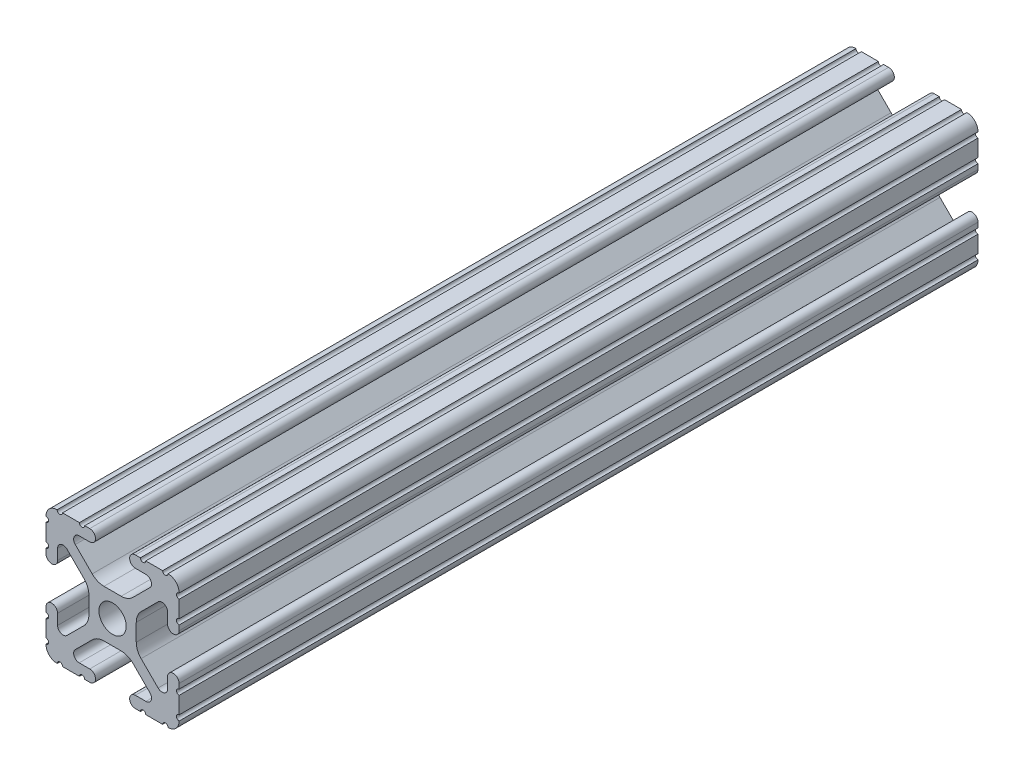
from build123d import *

# Parameters (mm, degrees)
SKETCH11_R              = 2.6035
FRACTIONAL_1010_1_DEPTH = 152.4


with BuildPart() as part:
    # Sketch11 → Fractional 1010(1) (new body)
    with BuildSketch(Plane.YX.offset(-76.2)):
        with BuildLine():
            Line((10.5918, 12.7), (10.5664, 12.7))
            ThreePointArc((10.5664, 12.7), (10.0584, 12.192), (9.5504, 12.7))
            Line((9.5504, 12.7), (6.3246, 12.7))
            ThreePointArc((6.3246, 12.7), (5.8166, 12.192), (5.3086, 12.7))
            Line((5.3086, 12.7), (4.3561, 12.7))
            ThreePointArc((4.3561, 12.7), (3.2512, 11.5951), (4.3561, 10.4902))
            Line((4.3561, 10.4902), (6.370083786, 10.4902))
            ThreePointArc((6.370083786, 10.4902), (7.348856743, 9.836204819), (7.119204175, 8.681663397))
            Line((7.119204175, 8.681663397), (3.88464389, 5.447103113))
            ThreePointArc((3.88464389, 5.447103113), (2.854599758, 4.758849627), (1.63957986, 4.517167143))
            Line((1.63957986, 4.517167143), (-1.63957986, 4.517167143))
            ThreePointArc((-1.63957986, 4.517167143), (-2.854599758, 4.758849627), (-3.88464389, 5.447103113))
            Line((-3.88464389, 5.447103113), (-7.119204175, 8.681663397))
            ThreePointArc((-7.119204175, 8.681663397), (-7.348856743, 9.836204819), (-6.370083786, 10.4902))
            Line((-6.370083786, 10.4902), (-4.3561, 10.4902))
            ThreePointArc((-4.3561, 10.4902), (-3.2512, 11.5951), (-4.3561, 12.7))
            Line((-4.3561, 12.7), (-5.3086, 12.7))
            ThreePointArc((-5.3086, 12.7), (-5.8166, 12.192), (-6.3246, 12.7))
            Line((-6.3246, 12.7), (-9.5504, 12.7))
            ThreePointArc((-9.5504, 12.7), (-10.0584, 12.192), (-10.5664, 12.7))
            Line((-10.5664, 12.7), (-10.5918, 12.7))
            ThreePointArc((-10.5918, 12.7), (-12.082522516, 12.082522516), (-12.7, 10.5918))
            Line((-12.7, 10.5918), (-12.7, 10.5664))
            ThreePointArc((-12.7, 10.5664), (-12.192, 10.0584), (-12.7, 9.5504))
            Line((-12.7, 9.5504), (-12.7, 6.3246))
            ThreePointArc((-12.7, 6.3246), (-12.192, 5.8166), (-12.7, 5.3086))
            Line((-12.7, 5.3086), (-12.7, 4.3561))
            ThreePointArc((-12.7, 4.3561), (-11.5951, 3.2512), (-10.4902, 4.3561))
            Line((-10.4902, 4.3561), (-10.4902, 6.370083786))
            ThreePointArc((-10.4902, 6.370083786), (-9.836204819, 7.348856743), (-8.681663397, 7.119204175))
            Line((-8.681663397, 7.119204175), (-5.447103113, 3.88464389))
            ThreePointArc((-5.447103113, 3.88464389), (-4.758849627, 2.854599758), (-4.517167143, 1.63957986))
            Line((-4.517167143, 1.63957986), (-4.517167143, -1.63957986))
            ThreePointArc((-4.517167143, -1.63957986), (-4.758849627, -2.854599758), (-5.447103113, -3.88464389))
            Line((-5.447103113, -3.88464389), (-8.681663397, -7.119204175))
            ThreePointArc((-8.681663397, -7.119204175), (-9.836204819, -7.348856743), (-10.4902, -6.370083786))
            Line((-10.4902, -6.370083786), (-10.4902, -4.3561))
            ThreePointArc((-10.4902, -4.3561), (-11.5951, -3.2512), (-12.7, -4.3561))
            Line((-12.7, -4.3561), (-12.7, -5.3086))
            ThreePointArc((-12.7, -5.3086), (-12.192, -5.8166), (-12.7, -6.3246))
            Line((-12.7, -6.3246), (-12.7, -9.5504))
            ThreePointArc((-12.7, -9.5504), (-12.192, -10.0584), (-12.7, -10.5664))
            Line((-12.7, -10.5664), (-12.7, -10.5918))
            ThreePointArc((-12.7, -10.5918), (-12.082522516, -12.082522516), (-10.5918, -12.7))
            Line((-10.5918, -12.7), (-10.5664, -12.7))
            ThreePointArc((-10.5664, -12.7), (-10.0584, -12.192), (-9.5504, -12.7))
            Line((-9.5504, -12.7), (-6.3246, -12.7))
            ThreePointArc((-6.3246, -12.7), (-5.8166, -12.192), (-5.3086, -12.7))
            Line((-5.3086, -12.7), (-4.3561, -12.7))
            ThreePointArc((-4.3561, -12.7), (-3.2512, -11.5951), (-4.3561, -10.4902))
            Line((-4.3561, -10.4902), (-6.370083786, -10.4902))
            ThreePointArc((-6.370083786, -10.4902), (-7.348856743, -9.836204819), (-7.119204175, -8.681663397))
            Line((-7.119204175, -8.681663397), (-3.88464389, -5.447103113))
            ThreePointArc((-3.88464389, -5.447103113), (-2.854599758, -4.758849627), (-1.63957986, -4.517167143))
            Line((-1.63957986, -4.517167143), (1.63957986, -4.517167143))
            ThreePointArc((1.63957986, -4.517167143), (2.854599758, -4.758849627), (3.88464389, -5.447103113))
            Line((3.88464389, -5.447103113), (7.119204175, -8.681663397))
            ThreePointArc((7.119204175, -8.681663397), (7.348856743, -9.836204819), (6.370083786, -10.4902))
            Line((6.370083786, -10.4902), (4.3561, -10.4902))
            ThreePointArc((4.3561, -10.4902), (3.2512, -11.5951), (4.3561, -12.7))
            Line((4.3561, -12.7), (5.3086, -12.7))
            ThreePointArc((5.3086, -12.7), (5.8166, -12.192), (6.3246, -12.7))
            Line((6.3246, -12.7), (9.5504, -12.7))
            ThreePointArc((9.5504, -12.7), (10.0584, -12.192), (10.5664, -12.7))
            Line((10.5664, -12.7), (10.5918, -12.7))
            ThreePointArc((10.5918, -12.7), (12.082522516, -12.082522516), (12.7, -10.5918))
            Line((12.7, -10.5918), (12.7, -10.5664))
            ThreePointArc((12.7, -10.5664), (12.192, -10.0584), (12.7, -9.5504))
            Line((12.7, -9.5504), (12.7, -6.3246))
            ThreePointArc((12.7, -6.3246), (12.192, -5.8166), (12.7, -5.3086))
            Line((12.7, -5.3086), (12.7, -4.3561))
            ThreePointArc((12.7, -4.3561), (11.5951, -3.2512), (10.4902, -4.3561))
            Line((10.4902, -4.3561), (10.4902, -6.370083786))
            ThreePointArc((10.4902, -6.370083786), (9.836204819, -7.348856743), (8.681663397, -7.119204175))
            Line((8.681663397, -7.119204175), (5.447103113, -3.88464389))
            ThreePointArc((5.447103113, -3.88464389), (4.758849627, -2.854599758), (4.517167143, -1.63957986))
            Line((4.517167143, -1.63957986), (4.517167143, 1.63957986))
            ThreePointArc((4.517167143, 1.63957986), (4.758849627, 2.854599758), (5.447103113, 3.88464389))
            Line((5.447103113, 3.88464389), (8.681663397, 7.119204175))
            ThreePointArc((8.681663397, 7.119204175), (9.836204819, 7.348856743), (10.4902, 6.370083786))
            Line((10.4902, 6.370083786), (10.4902, 4.3561))
            ThreePointArc((10.4902, 4.3561), (11.5951, 3.2512), (12.7, 4.3561))
            Line((12.7, 4.3561), (12.7, 5.3086))
            ThreePointArc((12.7, 5.3086), (12.192, 5.8166), (12.7, 6.3246))
            Line((12.7, 6.3246), (12.7, 9.5504))
            ThreePointArc((12.7, 9.5504), (12.192, 10.0584), (12.7, 10.5664))
            Line((12.7, 10.5664), (12.7, 10.5918))
            ThreePointArc((12.7, 10.5918), (12.082522516, 12.082522516), (10.5918, 12.7))
        make_face()
        Circle(SKETCH11_R, mode=Mode.SUBTRACT)
    extrude(amount=FRACTIONAL_1010_1_DEPTH)


solid = part.part
